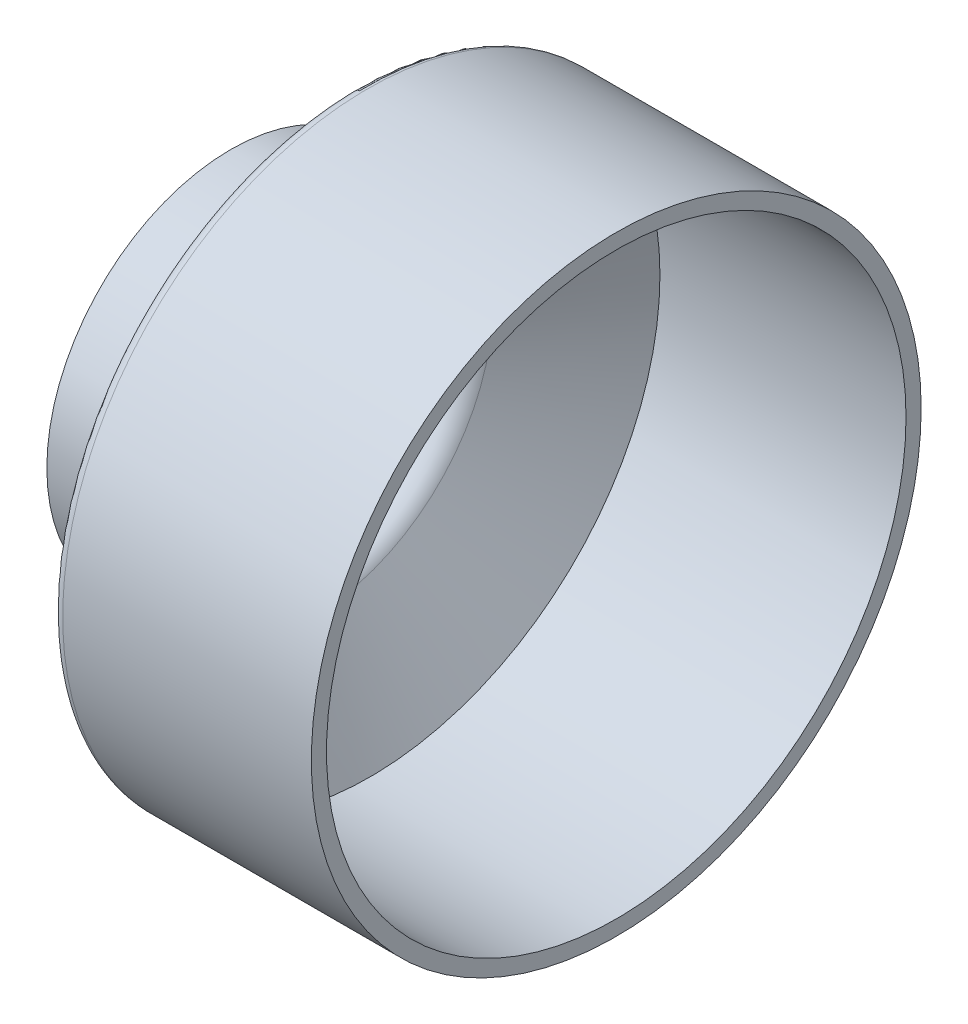
from build123d import *

# Parameters (mm, degrees)
SKETCH81_W          = 180
SKETCH81_H          = 433.466768404
EXTRUDE1_DEPTH      = 189
EXTRUDE1_DEPTH_BACK = 4.64655855
BOSS_EXTRUDE1_DEPTH = 25.4
BOSS_EXTRUDE2_DEPTH = 25.4
SCALE1_SCALE        = 0.99764556
SKETCH86_W          = 340
SKETCH86_H          = 440
CUT_EXTRUDE3_DEPTH  = 25.841374544
REVOLVE1_ANGLE      = 180


with BuildPart() as part:
    # Sketch1 → Revolve-Thin1 (revolve)
    with BuildSketch(Plane.XY, mode=Mode.PRIVATE) as revolve_thin1_sk:
        with BuildLine():
            Line((188, 191.7625), (57.01221252, 191.7625))
            ThreePointArc((57.01221252, 191.7625), (53.572316909, 190.822243935), (51.088985501, 188.262941607))
            Line((51.088985501, 188.262941607), (13.030109919, 119.174558393))
            ThreePointArc((13.030109919, 119.174558393), (10.546778511, 116.615256065), (7.1068829, 115.675))
            Line((7.1068829, 115.675), (-3.64655855, 115.675))
            Line((-3.64655855, 115.675), (-3.64655855, 106.15))
            Line((-3.64655855, 106.15), (7.1068829, 106.15))
            ThreePointArc((7.1068829, 106.15), (15.391881017, 108.41460934), (21.372991598, 114.578696092))
            Line((21.372991598, 114.578696092), (58.64435156, 182.2375))
            Line((58.64435156, 182.2375), (188, 182.2375))
            Line((188, 182.2375), (188, 191.7625))
        make_face()
    revolve(revolve_thin1_sk.sketch.rotate(Axis((0, 0, 0), (1, 0, 0)), 270), axis=Axis((0, 0, 0), (1, 0, 0)))  # turned: the seam where the file's is

    # Sketch81 → Extrude1 (cut, two sides)
    with BuildSketch(Plane(origin=(0, 0, 0), x_dir=(0, 0, -1), z_dir=(1, 0, 0))) as extrude1_sk:
        with Locations((-114.9, 1.572115024)):
            Rectangle(SKETCH81_W, SKETCH81_H)
    extrude(amount=EXTRUDE1_DEPTH, mode=Mode.SUBTRACT)
    extrude(extrude1_sk.sketch, amount=-EXTRUDE1_DEPTH_BACK, mode=Mode.SUBTRACT)

    # Sketch82 → Boss-Extrude1 (add)
    with BuildSketch(Plane.ZY.offset(3.64655855)):
        with BuildLine():
            Line((24.9, 103.188238186), (24.9, 112.963249002))
            ThreePointArc((24.9, 112.963249002), (-115.675, 0), (24.9, -112.963249002))
            Line((24.9, -112.963249002), (24.9, -103.188238186))
            ThreePointArc((24.9, -103.188238186), (-106.15, 0), (24.9, 103.188238186))
        make_face()
    extrude(amount=BOSS_EXTRUDE1_DEPTH)

    # Sketch83 → Boss-Extrude2 (add)
    with BuildSketch(Plane(origin=(188, 0, 0), x_dir=(0, 0, -1), z_dir=(1, 0, 0))):
        with BuildLine():
            Line((-24.9, -180.528381166), (-24.9, -190.139018632))
            ThreePointArc((-24.9, -190.139018632), (191.7625, 0), (-24.9, 190.139018632))
            Line((-24.9, 190.139018632), (-24.9, 180.528381166))
            ThreePointArc((-24.9, 180.528381166), (182.2375, 0), (-24.9, -180.528381166))
        make_face()
    extrude(amount=BOSS_EXTRUDE2_DEPTH)


with BuildPart() as part_1:
    # Scale1: scaled about (0, 0, 0)
    add(part.part.scale(SCALE1_SCALE))

    # Sketch86 → Cut-Extrude3 (cut, through all)
    with BuildSketch(Plane.XY):
        with Locations((100, 0)):
            Rectangle(SKETCH86_W, SKETCH86_H)
    extrude(amount=CUT_EXTRUDE3_DEPTH, mode=Mode.SUBTRACT)

    # Sketch87 → Revolve1 (revolve)
    with BuildSketch(Plane.XY):
        with BuildLine():
            Line((58.506276953, 181.808432741), (212.897562504, 181.808432741))
            Line((212.897562504, 181.808432741), (212.897562504, 191.3110067))
            Line((212.897562504, 191.3110067), (56.877980686, 191.3110067))
            ThreePointArc((56.877980686, 191.3110067), (53.446184103, 190.372964411), (50.96869955, 187.819687807))
            Line((50.96869955, 187.819687807), (12.999431307, 118.893969046))
            ThreePointArc((12.999431307, 118.893969046), (10.521946754, 116.340692442), (7.090150171, 115.402650153))
            Line((7.090150171, 115.402650153), (-28.978170171, 115.402650153))
            Line((-28.978170171, 115.402650153), (-28.978170171, 105.900076194))
            Line((-28.978170171, 105.900076194), (7.090150171, 105.900076194))
            ThreePointArc((7.090150171, 105.900076194), (15.355641757, 108.159353648), (21.322670172, 114.308927427))
            Line((21.322670172, 114.308927427), (58.506276953, 181.808432741))
        make_face()
    revolve(axis=Axis((224.991349138, 0, 0), (1, 0, 0)), revolution_arc=REVOLVE1_ANGLE)


solid = part_1.part
